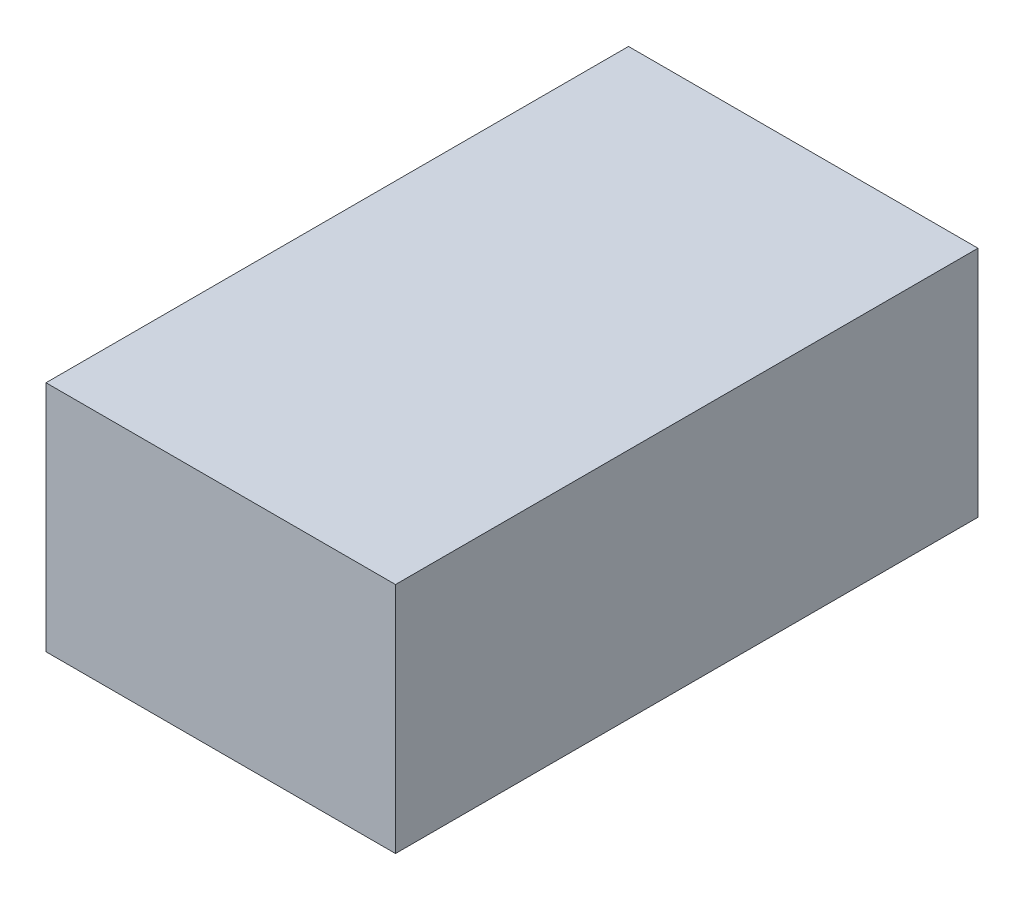
from build123d import *

# Parameters (mm, degrees)
SKETCH2_W           = 100
SKETCH2_H           = 40
BOSS_EXTRUDE1_DEPTH = 60


with BuildPart() as part:
    # Sketch2 → Boss-Extrude1 (new body)
    with BuildSketch(Plane(origin=(0, 0, 0), x_dir=(0, 0, -1), z_dir=(1, 0, 0))):
        Rectangle(SKETCH2_W, SKETCH2_H)
    extrude(amount=BOSS_EXTRUDE1_DEPTH)


solid = part.part
